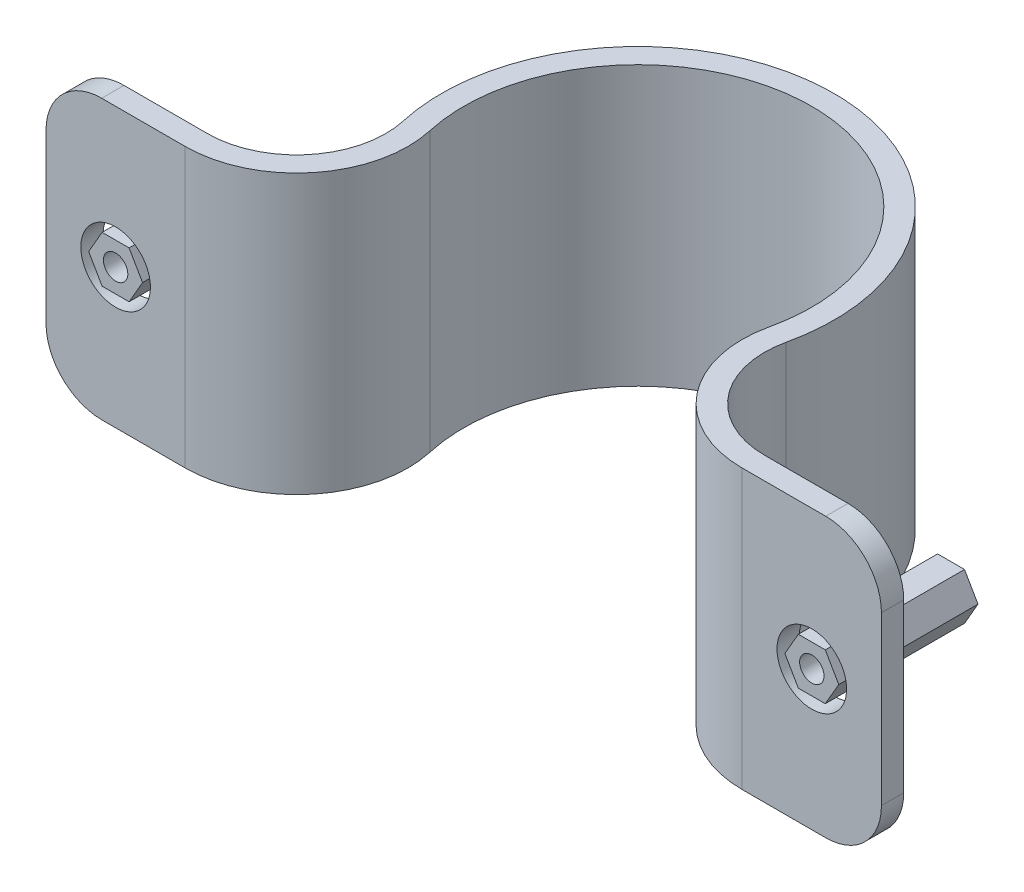
from build123d import *

# Parameters (mm, degrees)
BOSS_EXTRUDE1_DEPTH   = 25.4
FILLET1_R             = 5.08
SKETCH2_R             = 3.175
CUT_EXTRUDE1_DEPTH    = 3.032
SKETCH4_R             = 1.112492688
BOSS_EXTRUDE2_DEPTH   = 12.7
BOSS_EXTRUDE2_2_DEPTH = 12.7


with BuildPart() as part:
    # Sketch1 → Boss-Extrude1 (new body)
    with BuildSketch(Plane(origin=(0, 0, 0), x_dir=(1, 0, 0), z_dir=(0, 1, 0))):
        with BuildLine():
            Line((0, 31.75), (0, 33.782))
            ThreePointArc((0, 33.782), (13.983017771, 27.061414217), (17.470243902, 11.944195122))
            ThreePointArc((17.470243902, 11.944195122), (19.053098317, 5.082478653), (25.4, 2.032))
            Line((25.4, 2.032), (38.1, 2.032))
            Line((38.1, 2.032), (38.1, 0))
            Line((38.1, 0), (25.4, 0))
            ThreePointArc((25.4, 0), (17.466372896, 3.813098317), (15.487804878, 12.390243902))
            ThreePointArc((15.487804878, 12.390243902), (12.39629235, 25.79203388), (0, 31.75))
        make_face()
    boss_extrude1 = extrude(amount=BOSS_EXTRUDE1_DEPTH)

    # Mirror2: Boss-Extrude1 across plane
    add(boss_extrude1.mirror(Plane(origin=(0, 0, 0), x_dir=(0, 0, 1), z_dir=(1, 0, 0))))

    # Fillet1
    fillet1_edges = [part.edges().sort_by_distance(p)[0] for p in [
        (38.1, 25.4, -1.016),
        (-38.1, 25.4, -1.016),
        (-38.1, 0, -1.016),
        (38.1, 0, -1.016),
    ]]
    fillet(fillet1_edges, radius=FILLET1_R)

    # Sketch2 → Cut-Extrude1 (cut, through all)
    with BuildSketch(Plane(origin=(0, 0, -2.032), x_dir=(-1, 0, 0), z_dir=(0, 0, -1))):
        with Locations((-31.75, 12.7)):
            Circle(SKETCH2_R)
    cut_extrude1 = extrude(amount=-CUT_EXTRUDE1_DEPTH, mode=Mode.SUBTRACT)

    # Mirror1: Cut-Extrude1 across plane
    add(cut_extrude1.mirror(Plane(origin=(0, 0, 0), x_dir=(0, 0, 1), z_dir=(1, 0, 0))), mode=Mode.SUBTRACT)


with BuildPart() as body_2:
    # Sketch4 → Boss-Extrude2 (new body)
    with BuildSketch(Plane.XY):
        Polygon((-29.292228347, 12.7), (-30.521114173, 14.828492688), (-32.978885827, 14.828492688), (-34.207771653, 12.7), (-32.978885827, 10.571507312), (-30.521114173, 10.571507312), align=None)
        with Locations((-31.75, 12.7)):
            Circle(SKETCH4_R, mode=Mode.SUBTRACT)
    extrude(amount=-BOSS_EXTRUDE2_DEPTH)


with BuildPart() as body_3:
    # Sketch4 → Boss-Extrude2 2 (new body)
    with BuildSketch(Plane.XY):
        Polygon((30.521114173, 10.571507312), (29.292228347, 12.7), (30.521114173, 14.828492688), (32.978885827, 14.828492688), (34.207771653, 12.7), (32.978885827, 10.571507312), align=None)
        with Locations((31.75, 12.7)):
            Circle(SKETCH4_R, mode=Mode.SUBTRACT)
    extrude(amount=-BOSS_EXTRUDE2_2_DEPTH)


solid = Compound([part.part, body_2.part, body_3.part])
